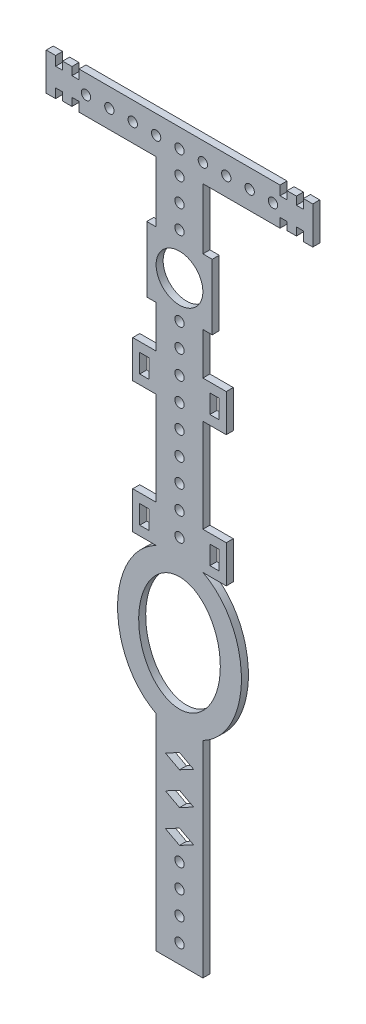
from build123d import *

# Parameters (mm, degrees)
SKETCH_1_W      = 2
SKETCH_1_H      = 4
SKETCH_1_R      = 1
SKETCH_1_R_2    = 5
EXTRUDE_1_DEPTH = 1.5


with BuildPart() as part:
    # 草图1 → 凸台-拉伸1 (new body)
    with BuildSketch(Plane.XY):
        with BuildLine():
            Line((21.499281064, 30), (-21.499281064, 30))
            Line((-21.499281064, 30), (-21.499281064, 28))
            Line((-21.499281064, 28), (-22.999281064, 28))
            Line((-22.999281064, 28), (-22.999281064, 29.7))
            Line((-22.999281064, 29.7), (-24.999281064, 29.7))
            Line((-24.999281064, 29.7), (-24.999281064, 28))
            Line((-24.999281064, 28), (-26.499281064, 28))
            Line((-26.499281064, 28), (-26.499281064, 30))
            Line((-26.499281064, 30), (-28.499281064, 30))
            Line((-28.499281064, 30), (-28.499281064, 22))
            Line((-28.499281064, 22), (-26.499281064, 22))
            Line((-26.499281064, 22), (-26.499281064, 24))
            Line((-26.499281064, 24), (-24.999281064, 24))
            Line((-24.999281064, 24), (-24.999281064, 22.3))
            Line((-24.999281064, 22.3), (-22.999281064, 22.3))
            Line((-22.999281064, 22.3), (-22.999281064, 24))
            Line((-22.999281064, 24), (-21.499281064, 24))
            Line((-21.499281064, 24), (-21.499281064, 22))
            Line((-21.499281064, 22), (-5, 22))
            Line((-5, 22), (-5, 9))
            Line((-5, 9), (-7, 9))
            Line((-7, 9), (-7, -5))
            Line((-7, -5), (-5, -5))
            Line((-5, -5), (-5, -14))
            Line((-5, -14), (-10, -14))
            Line((-10, -14), (-10, -22))
            Line((-10, -22), (-5, -22))
            Line((-5, -22), (-5, -42))
            Line((-5, -42), (-10, -42))
            Line((-10, -42), (-10, -50))
            Line((-10, -50), (-5, -50))
            add(Edge.make_bspline(
                [(-5, -50), (-5.206631572, -50.1046163), (-7.122538881, -51.146340962), (-10.136236083, -54.053937604), (-12.460991296, -59.031081614), (-13.257864896, -63.527529667), (-13.257864896, -67.592056821), (-12.460991296, -72.088504874), (-10.136236082, -77.065648884), (-7.122538881, -79.973245525), (-5.206631571, -81.014970188), (-5, -81.119586487)],
                knots=[3.487673016, 3.487673016, 3.487673016, 3.487673016, 3.534291735, 3.926990817, 4.319689899, 4.61421421, 4.810563751, 5.105088062, 5.497787144, 5.890486225, 5.937104944, 5.937104944, 5.937104944, 5.937104944], degree=3))
            Line((-5, -81.119586487), (-5, -125.119586487))
            Line((-5, -125.119586487), (5, -125.119586487))
            Line((5, -125.119586487), (5, -81.119586487))
            add(Edge.make_bspline(
                [(5, -81.119586487), (5.206631572, -81.014970188), (7.122538881, -79.973245525), (10.136236083, -77.065648883), (12.460991296, -72.088504873), (13.257864896, -67.592056821), (13.257864896, -63.527529666), (12.460991296, -59.031081614), (10.136236082, -54.053937604), (7.122538881, -51.146340962), (5.206631571, -50.1046163), (5, -50)],
                knots=[6.62926567, 6.62926567, 6.62926567, 6.62926567, 6.675884389, 7.068583471, 7.461282552, 7.755806864, 7.952156404, 8.246680716, 8.639379797, 9.032078879, 9.078697598, 9.078697598, 9.078697598, 9.078697598], degree=3))
            Line((5, -50), (10, -50))
            Line((10, -50), (10, -42))
            Line((10, -42), (5, -42))
            Line((5, -42), (5, -22))
            Line((5, -22), (10, -22))
            Line((10, -22), (10, -14))
            Line((10, -14), (5, -14))
            Line((5, -14), (5, -5))
            Line((5, -5), (7, -5))
            Line((7, -5), (7, 9))
            Line((7, 9), (5, 9))
            Line((5, 9), (5, 22))
            Line((5, 22), (21.499281064, 22))
            Line((21.499281064, 22), (21.499281064, 24))
            Line((21.499281064, 24), (22.999281064, 24))
            Line((22.999281064, 24), (22.999281064, 22.3))
            Line((22.999281064, 22.3), (24.999281064, 22.3))
            Line((24.999281064, 22.3), (24.999281064, 24))
            Line((24.999281064, 24), (26.499281064, 24))
            Line((26.499281064, 24), (26.499281064, 22))
            Line((26.499281064, 22), (28.499281064, 22))
            Line((28.499281064, 22), (28.499281064, 30))
            Line((28.499281064, 30), (26.499281064, 30))
            Line((26.499281064, 30), (26.499281064, 28))
            Line((26.499281064, 28), (24.999281064, 28))
            Line((24.999281064, 28), (24.999281064, 29.7))
            Line((24.999281064, 29.7), (22.999281064, 29.7))
            Line((22.999281064, 29.7), (22.999281064, 28))
            Line((22.999281064, 28), (21.499281064, 28))
            Line((21.499281064, 28), (21.499281064, 30))
        make_face()
        with Locations((-7.5, -46)):
            Rectangle(SKETCH_1_W, SKETCH_1_H, mode=Mode.SUBTRACT)
        with Locations((0, -46)):
            Circle(SKETCH_1_R, mode=Mode.SUBTRACT)
        with Locations((0, -41)):
            Circle(SKETCH_1_R, mode=Mode.SUBTRACT)
        with Locations((0, -36)):
            Circle(SKETCH_1_R, mode=Mode.SUBTRACT)
        with Locations((0, -31)):
            Circle(SKETCH_1_R, mode=Mode.SUBTRACT)
        with Locations((-7.5, -18)):
            Rectangle(SKETCH_1_W, SKETCH_1_H, mode=Mode.SUBTRACT)
        with Locations((0, -26)):
            Circle(SKETCH_1_R, mode=Mode.SUBTRACT)
        with Locations((0, -21)):
            Circle(SKETCH_1_R, mode=Mode.SUBTRACT)
        with Locations((0, -16)):
            Circle(SKETCH_1_R, mode=Mode.SUBTRACT)
        with Locations((0, -11)):
            Circle(SKETCH_1_R, mode=Mode.SUBTRACT)
        with Locations((-20, 25.95138361)):
            Circle(SKETCH_1_R, mode=Mode.SUBTRACT)
        with Locations((-15, 25.95138361)):
            Circle(SKETCH_1_R, mode=Mode.SUBTRACT)
        with Locations((0, -6)):
            Circle(SKETCH_1_R, mode=Mode.SUBTRACT)
        with Locations((0, 2)):
            Circle(SKETCH_1_R_2, mode=Mode.SUBTRACT)
        with Locations((-10, 25.95138361)):
            Circle(SKETCH_1_R, mode=Mode.SUBTRACT)
        with Locations((-5, 25.95138361)):
            Circle(SKETCH_1_R, mode=Mode.SUBTRACT)
        with Locations((0, 25.95138361)):
            Circle(SKETCH_1_R, mode=Mode.SUBTRACT)
        with Locations((7.5, -46)):
            Rectangle(SKETCH_1_W, SKETCH_1_H, mode=Mode.SUBTRACT)
        with Locations((7.5, -18)):
            Rectangle(SKETCH_1_W, SKETCH_1_H, mode=Mode.SUBTRACT)
        with Locations((0, 10.95138361)):
            Circle(SKETCH_1_R, mode=Mode.SUBTRACT)
        with Locations((0, 15.95138361)):
            Circle(SKETCH_1_R, mode=Mode.SUBTRACT)
        with Locations((0, 20.95138361)):
            Circle(SKETCH_1_R, mode=Mode.SUBTRACT)
        with Locations((5, 25.95138361)):
            Circle(SKETCH_1_R, mode=Mode.SUBTRACT)
        with Locations((10, 25.95138361)):
            Circle(SKETCH_1_R, mode=Mode.SUBTRACT)
        with Locations((15, 25.95138361)):
            Circle(SKETCH_1_R, mode=Mode.SUBTRACT)
        with Locations((20, 25.95138361)):
            Circle(SKETCH_1_R, mode=Mode.SUBTRACT)
        with BuildLine():
            add(Edge.make_bspline(
                [(0, -77.82152984), (15.11674465, -77.82152984), (7.558372325, -59.428924948), (0, -41.036320056), (-7.558372325, -59.428924948), (-15.11674465, -77.82152984), (0, -77.82152984)],
                knots=[0, 0, 0, 2.094395102, 2.094395102, 4.188790205, 4.188790205, 6.283185307, 6.283185307, 6.283185307], degree=2, weights=[1, 0.5, 1, 0.5, 1, 0.5, 1]))
        make_face(mode=Mode.SUBTRACT)
        Polygon((3, -87.457928946), (0, -89.061347215), (-3, -87.457928946), (0, -85.854510677), align=None, mode=Mode.SUBTRACT)
        with Locations((0, -121.119586487)):
            Circle(SKETCH_1_R, mode=Mode.SUBTRACT)
        with Locations((0, -116.119586487)):
            Circle(SKETCH_1_R, mode=Mode.SUBTRACT)
        with Locations((0, -111.119586487)):
            Circle(SKETCH_1_R, mode=Mode.SUBTRACT)
        with Locations((0, -106.119586487)):
            Circle(SKETCH_1_R, mode=Mode.SUBTRACT)
        Polygon((0, -99.854510677), (3, -101.457928946), (0, -103.061347215), (-3, -101.457928946), align=None, mode=Mode.SUBTRACT)
        Polygon((0, -92.854510677), (3, -94.457928946), (0, -96.061347215), (-3, -94.457928946), align=None, mode=Mode.SUBTRACT)
    extrude(amount=EXTRUDE_1_DEPTH)


solid = part.part
